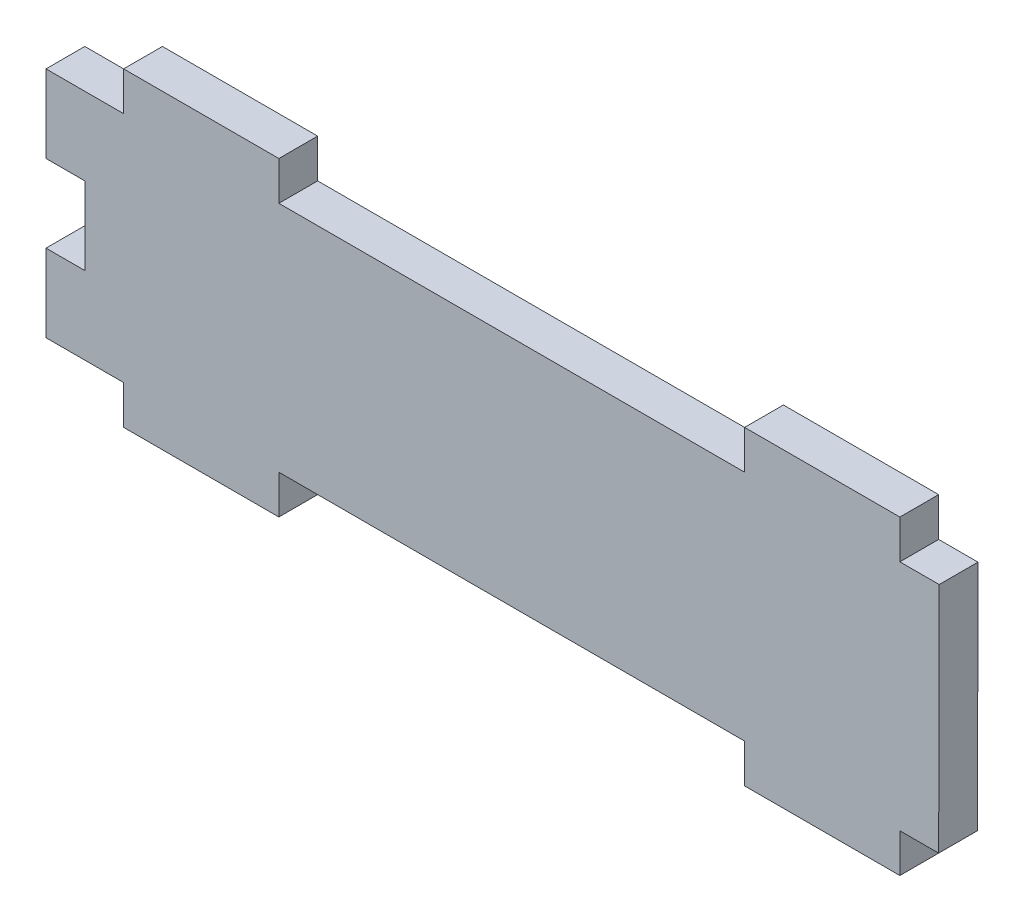
from build123d import *

# Parameters (mm, degrees)
BOSS_EXTRUDE1_DEPTH = 6.35


with BuildPart() as part:
    # Sketch1 → Boss-Extrude1 (new body)
    with BuildSketch(Plane.XY):
        Polygon((0, 44.45), (6.35, 44.45), (12.7, 44.45), (12.7, 50.8), (38.1, 50.8), (38.1, 44.45), (114.3, 44.45), (114.3, 50.8), (139.700500833, 50.8), (139.700500833, 44.449905779), (146.134732736, 44.449905779), (146.05, 6.35), (139.7, 6.35), (139.7, 0), (114.3, 0), (114.3, 6.35), (38.1, 6.35), (38.1, 0), (12.7, 0), (12.7, 6.35), (6.35, 6.35), (0, 6.35), (0, 19.05), (6.35, 19.05), (6.35, 31.75), (0, 31.75), align=None)
    extrude(amount=BOSS_EXTRUDE1_DEPTH)


solid = part.part
